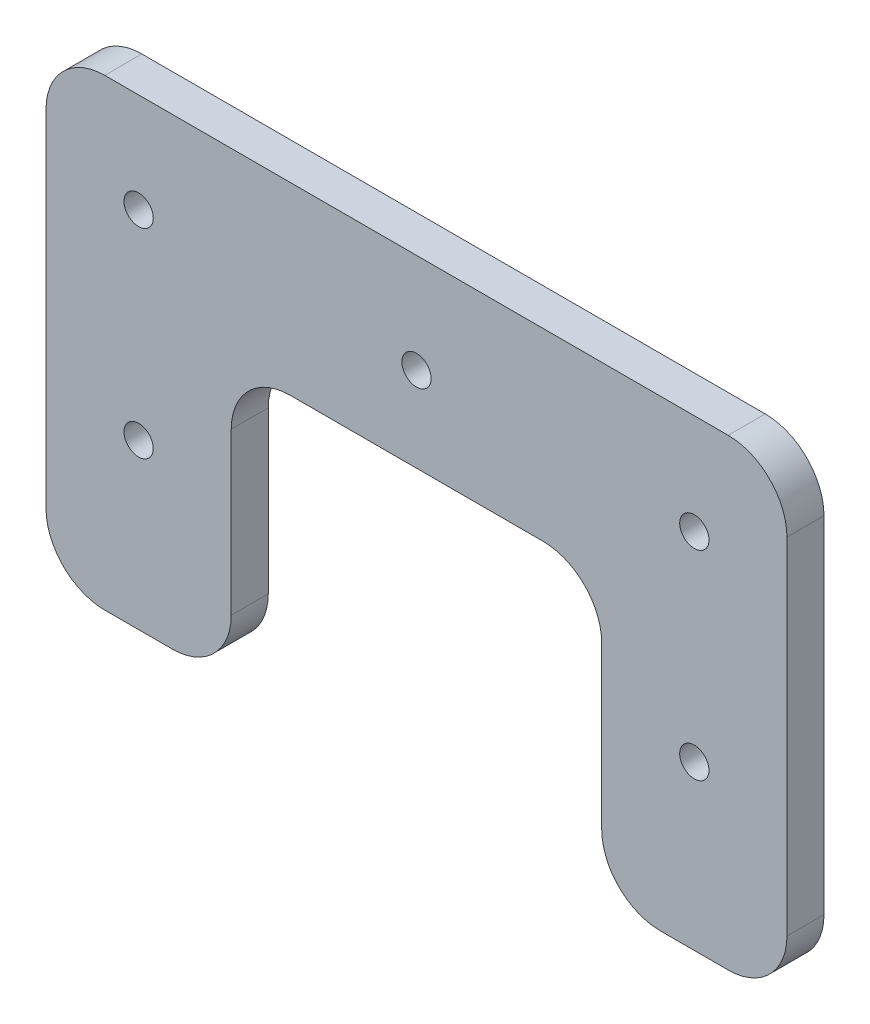
from build123d import *

# Parameters (mm, degrees)
CROQUIS1_R              = 1.58
SALIENTE_EXTRUIR1_DEPTH = 4


with BuildPart() as part:
    # Croquis1 → Saliente-Extruir1 (new body)
    with BuildSketch(Plane.XY):
        with BuildLine():
            Line((26.538050923, 6.699416954), (53.838050923, 6.699416954))
            ThreePointArc((53.838050923, 6.699416954), (58.328178983, 4.839545014), (60.188050923, 0.349416954))
            Line((60.188050923, 0.349416954), (60.188050923, -17.045643676))
            ThreePointArc((60.188050923, -17.045643676), (62.047922862, -21.535771736), (66.538050923, -23.395643676))
            Line((66.538050923, -23.395643676), (73.838050923, -23.395643676))
            ThreePointArc((73.838050923, -23.395643676), (78.328178983, -21.535771736), (80.188050923, -17.045643676))
            Line((80.188050923, -17.045643676), (80.188050923, 6.604356324))
            Line((80.188050923, 6.604356324), (80.188050923, 20.254356324))
            ThreePointArc((80.188050923, 20.254356324), (78.328178983, 24.744484385), (73.838050923, 26.604356324))
            Line((73.838050923, 26.604356324), (6.538050923, 26.604356324))
            ThreePointArc((6.538050923, 26.604356324), (2.047922862, 24.744484385), (0.188050923, 20.254356324))
            Line((0.188050923, 20.254356324), (0.188050923, 6.604356324))
            Line((0.188050923, 6.604356324), (0.188050923, -17.045643676))
            ThreePointArc((0.188050923, -17.045643676), (2.047922862, -21.535771736), (6.538050923, -23.395643676))
            Line((6.538050923, -23.395643676), (13.838050923, -23.395643676))
            ThreePointArc((13.838050923, -23.395643676), (18.328178983, -21.535771736), (20.188050923, -17.045643676))
            Line((20.188050923, -17.045643676), (20.188050923, 0.349416954))
            ThreePointArc((20.188050923, 0.349416954), (22.047922862, 4.839545014), (26.538050923, 6.699416954))
        make_face()
        with Locations((40.188050923, 15.866498333)):
            Circle(CROQUIS1_R, mode=Mode.SUBTRACT)
        with Locations((10.188050923, 15.866498333)):
            Circle(CROQUIS1_R, mode=Mode.SUBTRACT)
        with Locations((70.188050923, 15.771437703)):
            Circle(CROQUIS1_R, mode=Mode.SUBTRACT)
        with Locations((10.188050923, -5.676497666)):
            Circle(CROQUIS1_R, mode=Mode.SUBTRACT)
        with Locations((70.188050923, -5.771558296)):
            Circle(CROQUIS1_R, mode=Mode.SUBTRACT)
    extrude(amount=SALIENTE_EXTRUIR1_DEPTH)


solid = part.part
